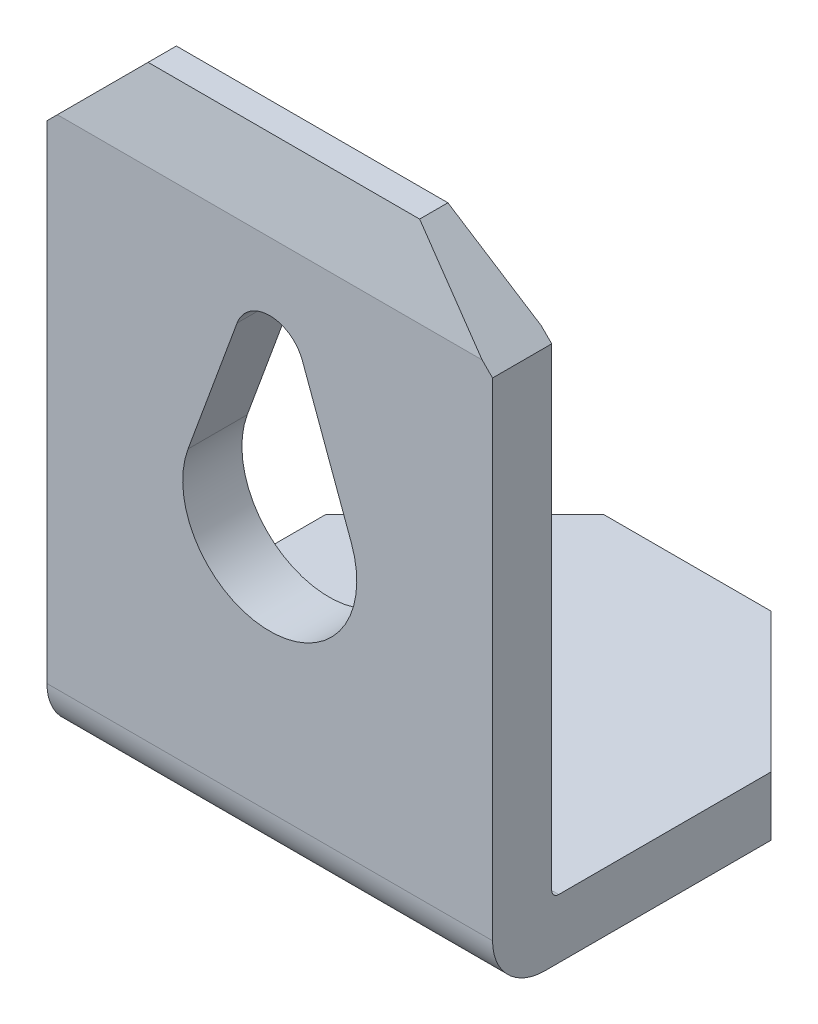
from build123d import *

# Parameters (mm, degrees)
BOSS_EXTRUDE1_DEPTH = 6.4
CHAMFER3_SIZE       = 2
CUT_EXTRUDE1_DEPTH  = 0.85
CUT_EXTRUDE2_DEPTH  = 0.85


with BuildPart() as part:
    # Sketch1 → Boss-Extrude1 (new body)
    with BuildSketch(Plane(origin=(0, 0, 0), x_dir=(0, 0, -1), z_dir=(1, 0, 0))):
        with BuildLine():
            Line((0, 0.1), (0, 7.05))
            Line((0, 7.05), (-0.241393443, 8.15))
            Line((-0.241393443, 8.15), (-0.647131148, 8.15))
            Line((-0.647131148, 8.15), (-0.85, 7.05))
            Line((-0.85, 7.05), (-0.85, -0.1))
            ThreePointArc((-0.85, -0.1), (-0.630330086, -0.630330086), (-0.1, -0.85))
            Line((-0.1, -0.85), (5.15, -0.85))
            Line((5.15, -0.85), (5.15, 0))
            Line((5.15, 0), (0.1, 0))
            ThreePointArc((0.1, 0), (0.029289322, 0.029289322), (0, 0.1))
        make_face()
    extrude(amount=BOSS_EXTRUDE1_DEPTH)

    # Chamfer3
    chamfer3_edges = [part.edges().sort_by_distance(p)[0] for p in [
        (0, -0.425, -5.15),
        (6.4, -0.425, -5.15),
    ]]
    chamfer(chamfer3_edges, length=CHAMFER3_SIZE)

    # Sketch4 → Cut-Extrude1 (cut)
    with BuildSketch(Plane.XY.offset(0.85)):
        Polygon((0, 6.9), (1.25, 8.15), (0, 8.15), align=None)
        Polygon((5.15, 8.15), (6.4, 6.9), (6.4, 8.15), align=None)
    extrude(amount=-CUT_EXTRUDE1_DEPTH, mode=Mode.SUBTRACT)

    # Sketch5 → Cut-Extrude2 (cut)
    with BuildSketch(Plane.XY.offset(0.85)):
        with BuildLine():
            Line((2.730622244, 5.748829869), (2.026555611, 3.830729922))
            ThreePointArc((2.026555611, 3.830729922), (3.20000017, 2.15), (4.373444272, 3.830730241))
            Line((4.373444272, 3.830730241), (3.669633952, 5.748130298))
            ThreePointArc((3.669633952, 5.748130298), (3.200372504, 6.076537762), (2.730622244, 5.748829869))
        make_face()
    extrude(amount=-CUT_EXTRUDE2_DEPTH, mode=Mode.SUBTRACT)


solid = part.part
